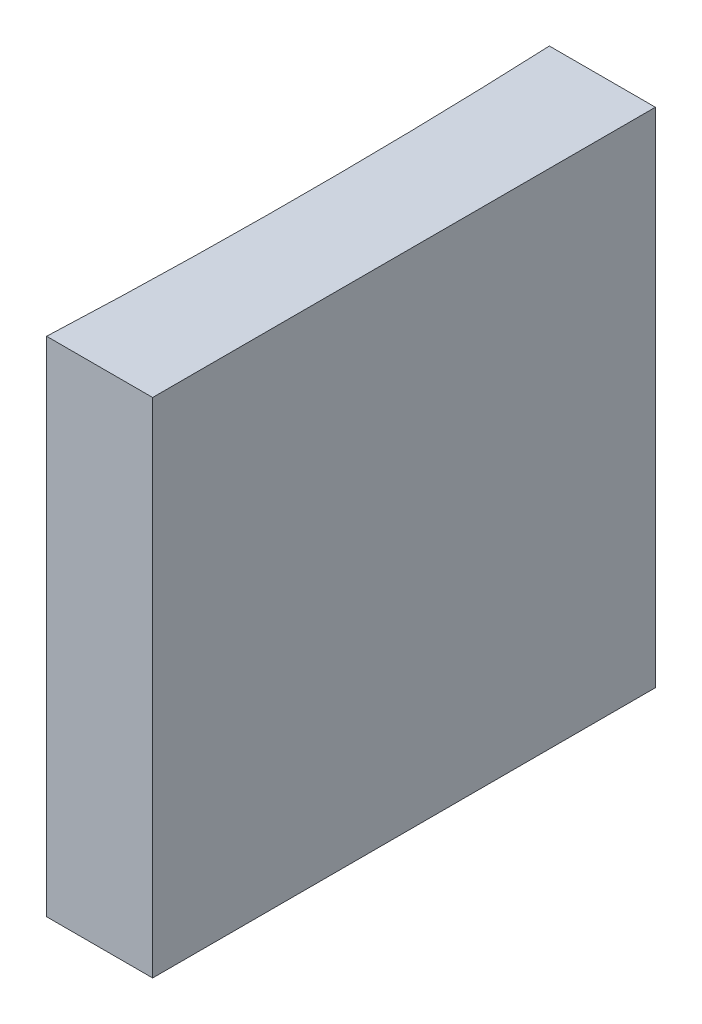
from build123d import *

# Parameters (mm, degrees)
EXTRUDE_1_DEPTH = 10


with BuildPart() as part:
    # 草图1 → 凸台-拉伸1 (new body)
    with BuildSketch(Plane(origin=(0, 0, 0), x_dir=(1, 0, 0), z_dir=(0, 1, 0))):
        with BuildLine():
            Line((0, 0), (0, -10))
            Line((0, -10), (-2.109107942, -10))
            ThreePointArc((-2.109107942, -10), (-2, -5), (-2.109107942, 0))
            Line((-2.109107942, 0), (0, 0))
        make_face()
    extrude(amount=EXTRUDE_1_DEPTH)


solid = part.part
